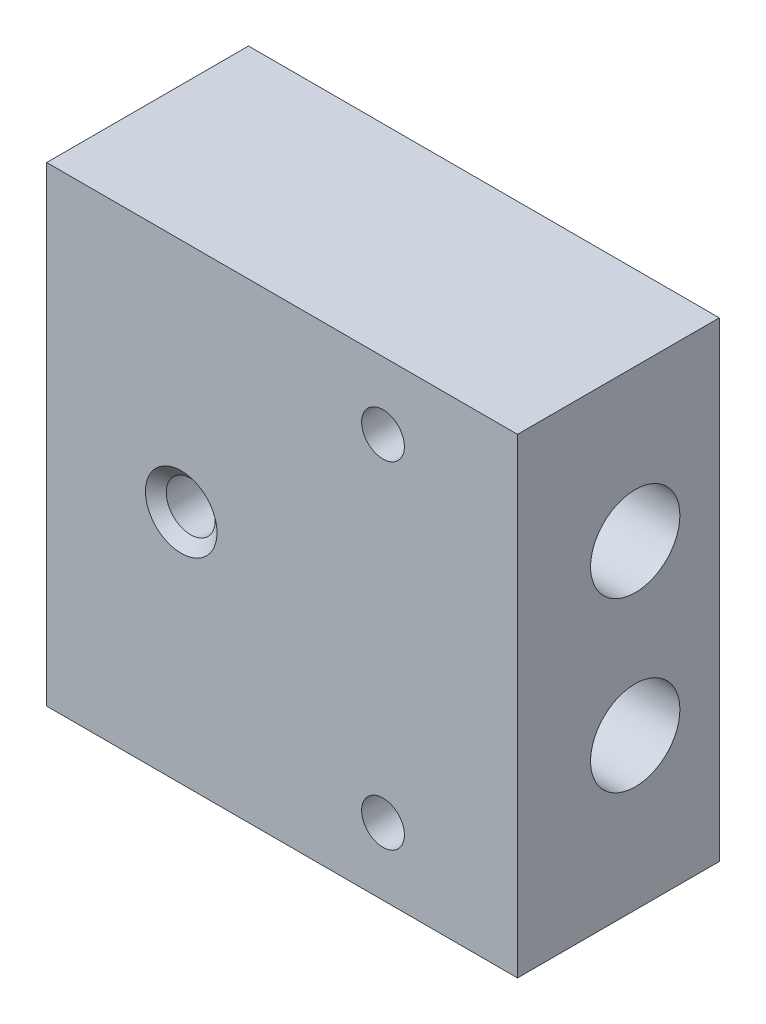
from build123d import *

# Parameters (mm, degrees)
SKETCH1_W                         = 44.45
SKETCH1_H                         = 44.45
BOSS_EXTRUDE1_DEPTH               = 19.05
F_12_28_TAPPED_HOLE1_D            = 4.6228
F_12_28_TAPPED_HOLE1_DEPTH        = 11.43
F_12_28_TAPPED_HOLE1_CSINK_D      = 6.7564
F_12_28_TAPPED_HOLE1_CSINK_ANGLE  = 100
F_12_28_TAPPED_HOLE1_TIP          = 1.388829235
PIPE_TAP_DRILL_FOR_1_8_TAP1_D     = 8.4328
PIPE_TAP_DRILL_FOR_1_8_TAP1_DEPTH = 35.052
PIPE_TAP_DRILL_FOR_1_8_TAP1_TIP   = 2.533468714
F_10_32_TAPPED_HOLE1_D            = 4.0386
F_3_8_24_TAPPED_HOLE1_D           = 8.4328
F_3_8_24_TAPPED_HOLE1_DEPTH       = 9.652
F_3_8_24_TAPPED_HOLE1_TIP         = 2.533468714


with BuildPart() as part:
    # Sketch1 → Boss-Extrude1 (new body)
    with BuildSketch(Plane.XY):
        Rectangle(SKETCH1_W, SKETCH1_H)
    extrude(amount=BOSS_EXTRUDE1_DEPTH)

    # #12-28 Tapped Hole1
    with Locations(Plane.XY.offset(19.05)):
        with Locations((-9.525, 0)):
            CounterSinkHole(F_12_28_TAPPED_HOLE1_D / 2, F_12_28_TAPPED_HOLE1_CSINK_D / 2, depth=F_12_28_TAPPED_HOLE1_DEPTH, counter_sink_angle=F_12_28_TAPPED_HOLE1_CSINK_ANGLE)
            with Locations((0, 0, -(F_12_28_TAPPED_HOLE1_DEPTH + F_12_28_TAPPED_HOLE1_TIP / 2))):  # 118° drill point
                Cone(0, F_12_28_TAPPED_HOLE1_D / 2, F_12_28_TAPPED_HOLE1_TIP, mode=Mode.SUBTRACT)

    # Pipe Tap Drill for 1/8 Tap1
    with Locations(Plane(origin=(22.225, 0, 0), x_dir=(0, 0, -1), z_dir=(1, 0, 0))):
        with Locations((-7.9375, 7.9375), (-7.9375, -7.9375)):
            Hole(PIPE_TAP_DRILL_FOR_1_8_TAP1_D / 2, depth=PIPE_TAP_DRILL_FOR_1_8_TAP1_DEPTH)
            with Locations((0, 0, -(PIPE_TAP_DRILL_FOR_1_8_TAP1_DEPTH + PIPE_TAP_DRILL_FOR_1_8_TAP1_TIP / 2))):  # 118° drill point
                Cone(0, PIPE_TAP_DRILL_FOR_1_8_TAP1_D / 2, PIPE_TAP_DRILL_FOR_1_8_TAP1_TIP, mode=Mode.SUBTRACT)

    # #10-32 Tapped Hole1 (through all)
    with Locations(Plane.XY.offset(19.05)):
        with Locations((9.525, 15.875), (9.525, -15.875)):
            Hole(F_10_32_TAPPED_HOLE1_D / 2)

    # 3/8-24 Tapped Hole1
    with Locations(Plane(origin=(0, 0, 0), x_dir=(-1, 0, 0), z_dir=(0, 0, -1))):
        with Locations((9.525, 0)):
            Hole(F_3_8_24_TAPPED_HOLE1_D / 2, depth=F_3_8_24_TAPPED_HOLE1_DEPTH)
            with Locations((0, 0, -(F_3_8_24_TAPPED_HOLE1_DEPTH + F_3_8_24_TAPPED_HOLE1_TIP / 2))):  # 118° drill point
                Cone(0, F_3_8_24_TAPPED_HOLE1_D / 2, F_3_8_24_TAPPED_HOLE1_TIP, mode=Mode.SUBTRACT)


solid = part.part
